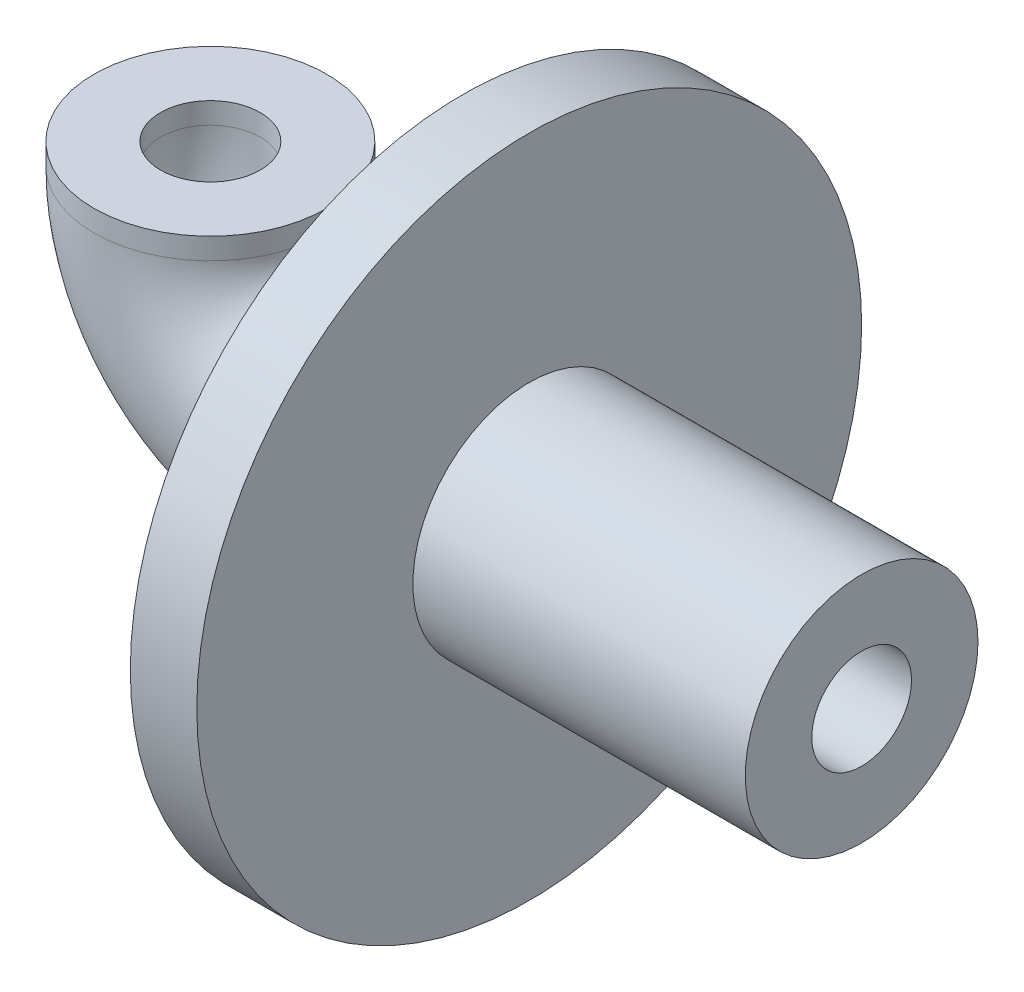
from build123d import *

# Parameters (mm, degrees)
SKETCH1_R           = 5
BOSS_EXTRUDE1_DEPTH = 1
SKETCH2_R           = 1.75
SKETCH2_R_2         = 0.75
BOSS_EXTRUDE2_DEPTH = 5
SKETCH4_R           = 0.75
CUT_EXTRUDE1_DEPTH  = 10
SKETCH5_R           = 1.75
SKETCH5_R_2         = 0.75


with BuildPart() as part:
    # Sketch1 → Boss-Extrude1 (new body)
    with BuildSketch(Plane(origin=(0, 0, 0), x_dir=(0, 0, -1), z_dir=(1, 0, 0))):
        Circle(SKETCH1_R)
    extrude(amount=BOSS_EXTRUDE1_DEPTH)

    # Sketch2 → Boss-Extrude2 (add)
    with BuildSketch(Plane(origin=(1, 0, 0), x_dir=(0, 0, -1), z_dir=(1, 0, 0))):
        Circle(SKETCH2_R)
        Circle(SKETCH2_R_2, mode=Mode.SUBTRACT)
    extrude(amount=BOSS_EXTRUDE2_DEPTH)

    # Sketch4 → Cut-Extrude1 (cut)
    with BuildSketch(Plane.ZY):
        Circle(SKETCH4_R)
    extrude(amount=-CUT_EXTRUDE1_DEPTH, mode=Mode.SUBTRACT)

    # Sweep5: sweep along a path in Sketch6
    with BuildLine(Plane.XY) as sweep5_path:
        Line((0, 1.75), (-1.62315873, 1.75))
        ThreePointArc((-1.62315873, 1.75), (-1.921825037, 1.873711635), (-2.045536672, 2.172377942))
        Line((-2.045536672, 2.172377942), (-2.045536672, 2.4927445))
    # Sketch5 → Sweep5 (sweep)
    with BuildSketch(Plane.ZY):
        Circle(SKETCH5_R)
        Circle(SKETCH5_R_2, mode=Mode.SUBTRACT)
    sweep(path=sweep5_path.line)


solid = part.part
